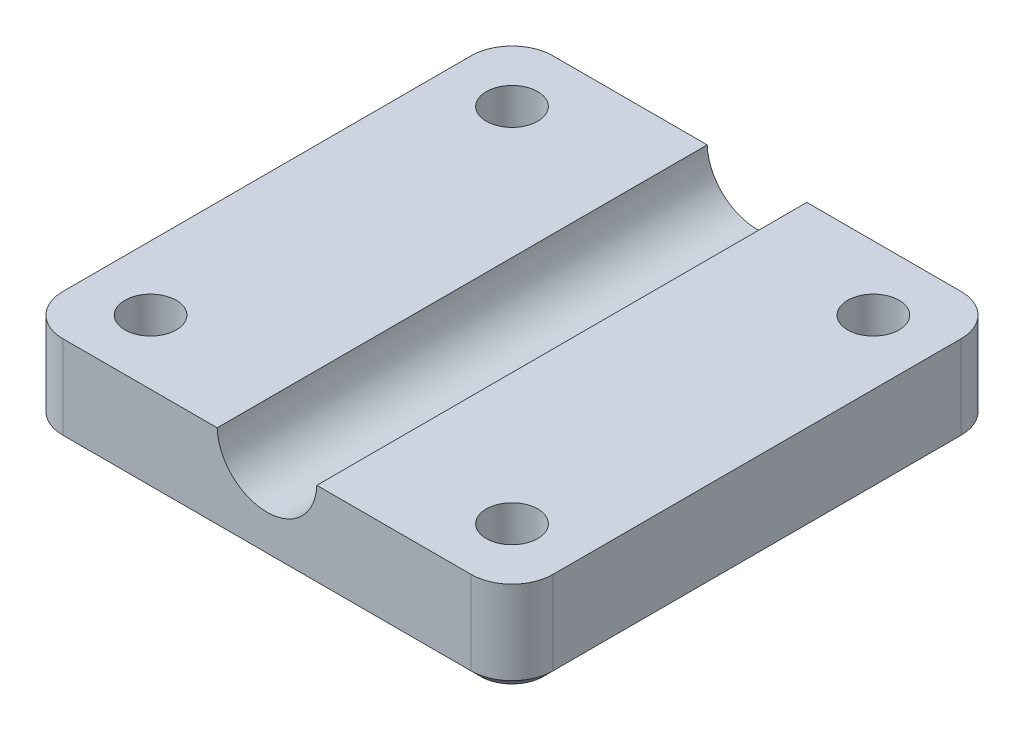
from build123d import *

# Parameters (mm, degrees)
SKETCH_2_W          = 30.48
SKETCH_2_H          = 30.48
EXTRUDE_1_DEPTH     = 5.8
SKETCH_3_R          = 3.1
CUT_EXTRUDE_1_DEPTH = 30.48
CUT_EXTRUDE_2_DEPTH = 2.5
SKETCH_5_R          = 1.6
CUT_EXTRUDE_3_DEPTH = 3.3
FILLET_1_R          = 2.54
CHAMFER_1_SIZE      = 0.6


with BuildPart() as part:
    # 草图2 → 凸台-拉伸1 (new body)
    with BuildSketch(Plane(origin=(0, 0, 0), x_dir=(1, 0, 0), z_dir=(0, 1, 0))):
        Rectangle(SKETCH_2_W, SKETCH_2_H)
    extrude(amount=EXTRUDE_1_DEPTH)

    # 草图3 → 切除-拉伸1 (cut)
    with BuildSketch(Plane.XY.offset(15.24)):
        with Locations((0, 5.9)):
            Circle(SKETCH_3_R)
    extrude(amount=-CUT_EXTRUDE_1_DEPTH, mode=Mode.SUBTRACT)

    # 草图4 → 切除-拉伸2 (cut)
    with BuildSketch(Plane.XZ):
        Polygon((13.567015256, 13.567015256), (10.388253301, 14.418761954), (8.061238046, 12.091746699), (8.912984744, 8.912984744), (12.091746699, 8.061238046), (14.418761954, 10.388253301), align=None)
        Polygon((-13.567015256, 13.567015256), (-14.418761954, 10.388253301), (-12.091746699, 8.061238046), (-8.912984744, 8.912984744), (-8.061238046, 12.091746699), (-10.388253301, 14.418761954), align=None)
        Polygon((13.567015256, -13.567015256), (14.418761954, -10.388253301), (12.091746699, -8.061238046), (8.912984744, -8.912984744), (8.061238046, -12.091746699), (10.388253301, -14.418761954), align=None)
        Polygon((-13.567015256, -13.567015256), (-10.388253301, -14.418761954), (-8.061238046, -12.091746699), (-8.912984744, -8.912984744), (-12.091746699, -8.061238046), (-14.418761954, -10.388253301), align=None)
    extrude(amount=-CUT_EXTRUDE_2_DEPTH, mode=Mode.SUBTRACT)

    # 草图5 → 切除-拉伸3 (cut)
    with BuildSketch(Plane(origin=(0, 2.5, 0), x_dir=(-1, 0, 0), z_dir=(0, -1, 0))):
        with Locations((11.24, -11.24)):
            Circle(SKETCH_5_R)
        with Locations((-11.24, -11.24)):
            Circle(SKETCH_5_R)
        with Locations((-11.24, 11.24)):
            Circle(SKETCH_5_R)
        with Locations((11.24, 11.24)):
            Circle(SKETCH_5_R)
    extrude(amount=-CUT_EXTRUDE_3_DEPTH, mode=Mode.SUBTRACT)

    # 圆角1
    fillet_1_edges = [part.edges().sort_by_distance(p)[0] for p in [
        (15.24, 2.9, 15.24),
        (-15.24, 2.9, 15.24),
        (-15.24, 2.9, -15.24),
        (15.24, 2.9, -15.24),
    ]]
    fillet(fillet_1_edges, radius=FILLET_1_R)

    # 倒角1
    chamfer_1_edges = [part.edges().sort_by_distance(p)[0] for p in [
        (-15.24, 0, 0),
        (15.24, 0, 0),
        (0, 0, 15.24),
        (0, 0, -15.24),
        (14.496051224, 0, -14.496051224),
        (14.496051224, 0, 14.496051224),
        (-14.496051224, 0, 14.496051224),
        (-14.496051224, 0, -14.496051224),
    ]]
    chamfer(chamfer_1_edges, length=CHAMFER_1_SIZE)


solid = part.part
